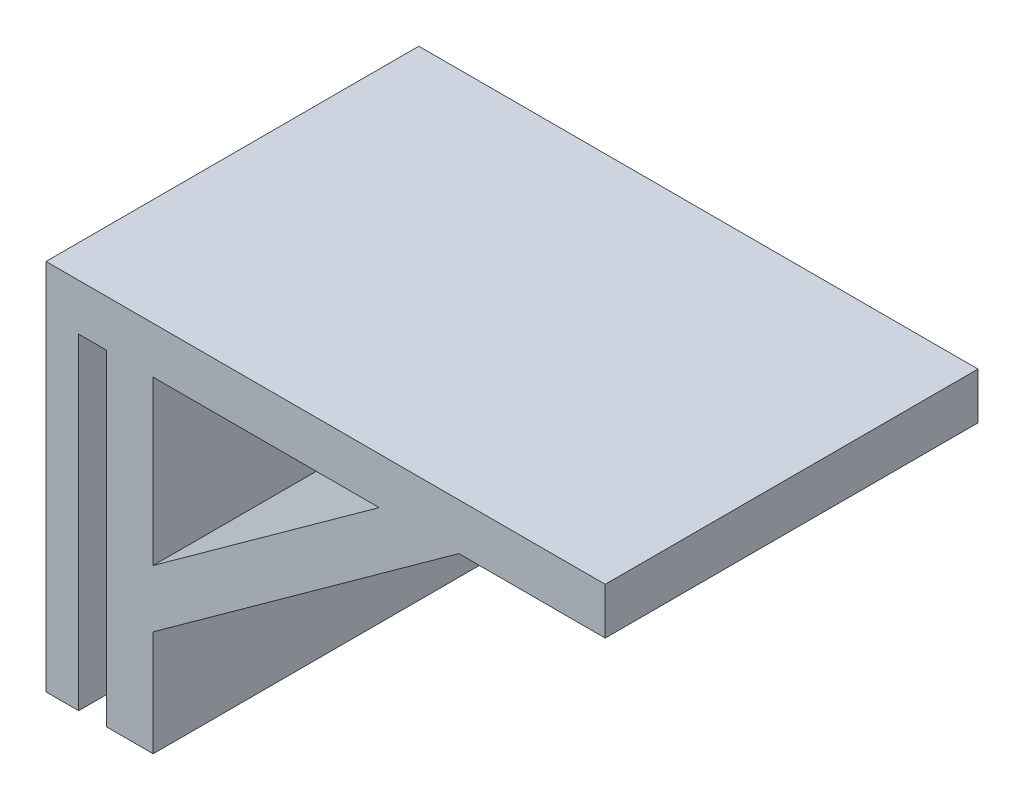
from build123d import *

# Parameters (mm, degrees)
BOSS_EXTRU_1_DEPTH = 80
BOSS_EXTRU_3_DEPTH = 80


with BuildPart() as part:
    # Esquisse1 → Boss.-Extru.1 (new body)
    with BuildSketch(Plane.XY):
        Polygon((0, 0), (0, 80), (120, 80), (120, 70), (23, 70), (23, 0), (13, 0), (13, 70), (7, 70), (7, 0), align=None)
    extrude(amount=BOSS_EXTRU_1_DEPTH)

    # Esquisse2 → Boss.-Extru.3 (add)
    with BuildSketch(Plane(origin=(0, 0, 0), x_dir=(-1, 0, 0), z_dir=(0, 0, -1))):
        Polygon((-71.5, 70), (-23, 35), (-23, 22.668017278), (-88.588604629, 70), align=None)
    extrude(amount=-BOSS_EXTRU_3_DEPTH)


solid = part.part
